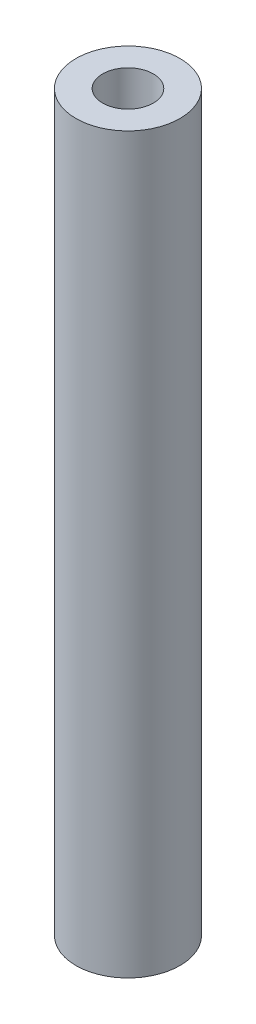
from build123d import *

# Parameters (mm, degrees)
SKETCH1_R           = 3.9
SKETCH1_R_2         = 1.9
BOSS_EXTRUDE1_DEPTH = 55


with BuildPart() as part:
    # Sketch1 → Boss-Extrude1 (new body)
    with BuildSketch(Plane(origin=(0, 0, 0), x_dir=(1, 0, 0), z_dir=(0, 1, 0))):
        Circle(SKETCH1_R)
        Circle(SKETCH1_R_2, mode=Mode.SUBTRACT)
    extrude(amount=BOSS_EXTRUDE1_DEPTH)


solid = part.part
